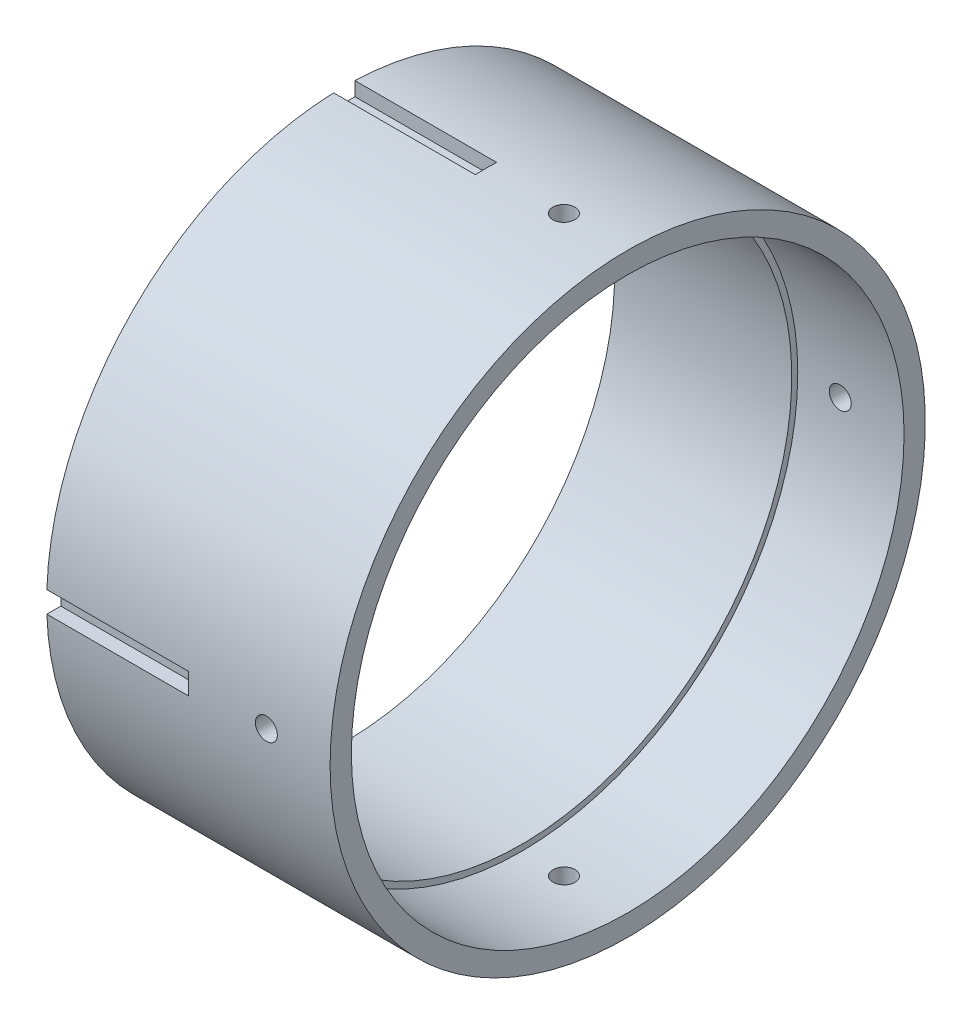
from build123d import *

# Parameters (mm, degrees)
D_GAGEMENT_M2_51_D           = 3.1
R_P_TITION_CIRCULAIRE1_COUNT = 2
R_P_TITION_CIRCULAIRE1_ANGLE = 90
ESQUISSE5_W                  = 3
ESQUISSE5_H                  = 15
ENL_V_MAT_EXTRU_1_DEPTH      = 20
R_P_TITION_CIRCULAIRE2_COUNT = 4


with BuildPart() as part:
    # Esquisse1 → Révolution1 (revolve)
    with BuildSketch(Plane.XY):
        Polygon((0, 38.15), (25, 38.15), (25, 39), (40, 39), (40, 42), (0, 42), align=None)
    revolve(axis=Axis((0, 0, 0), (1, 0, 0)))

    # Dégagement M2.51 (through all)
    with Locations(Plane(origin=(31, 42, 0), x_dir=(0, 0, 1), z_dir=(0, 1, 0))):
        with Locations((0, 0)):
            d_gagement_m2_51 = Hole(D_GAGEMENT_M2_51_D / 2)

    # Répétition circulaire1: Dégagement M2.51 ×2 about axis
    r_p_tition_circulaire1_axis = Axis((40, 0, 0), (-1, 0, 0))
    for i in range(1, R_P_TITION_CIRCULAIRE1_COUNT):
        add(d_gagement_m2_51.rotate(r_p_tition_circulaire1_axis, i * R_P_TITION_CIRCULAIRE1_ANGLE / (R_P_TITION_CIRCULAIRE1_COUNT - 1)), mode=Mode.SUBTRACT)

    # Esquisse5 → Enlèv. mat.-Extru.1 (cut)
    with BuildSketch(Plane.ZY):
        with Locations((0, 47.5)):
            Rectangle(ESQUISSE5_W, ESQUISSE5_H)
    enl_v_mat_extru_1 = extrude(amount=-ENL_V_MAT_EXTRU_1_DEPTH, mode=Mode.SUBTRACT)

    # Répétition circulaire2: Enlèv. mat.-Extru.1 ×4 about axis
    r_p_tition_circulaire2_axis = Axis((0, 0, 0), (1, 0, 0))
    for i in range(1, R_P_TITION_CIRCULAIRE2_COUNT):
        add(enl_v_mat_extru_1.rotate(r_p_tition_circulaire2_axis, i * 360 / R_P_TITION_CIRCULAIRE2_COUNT), mode=Mode.SUBTRACT)


solid = part.part
